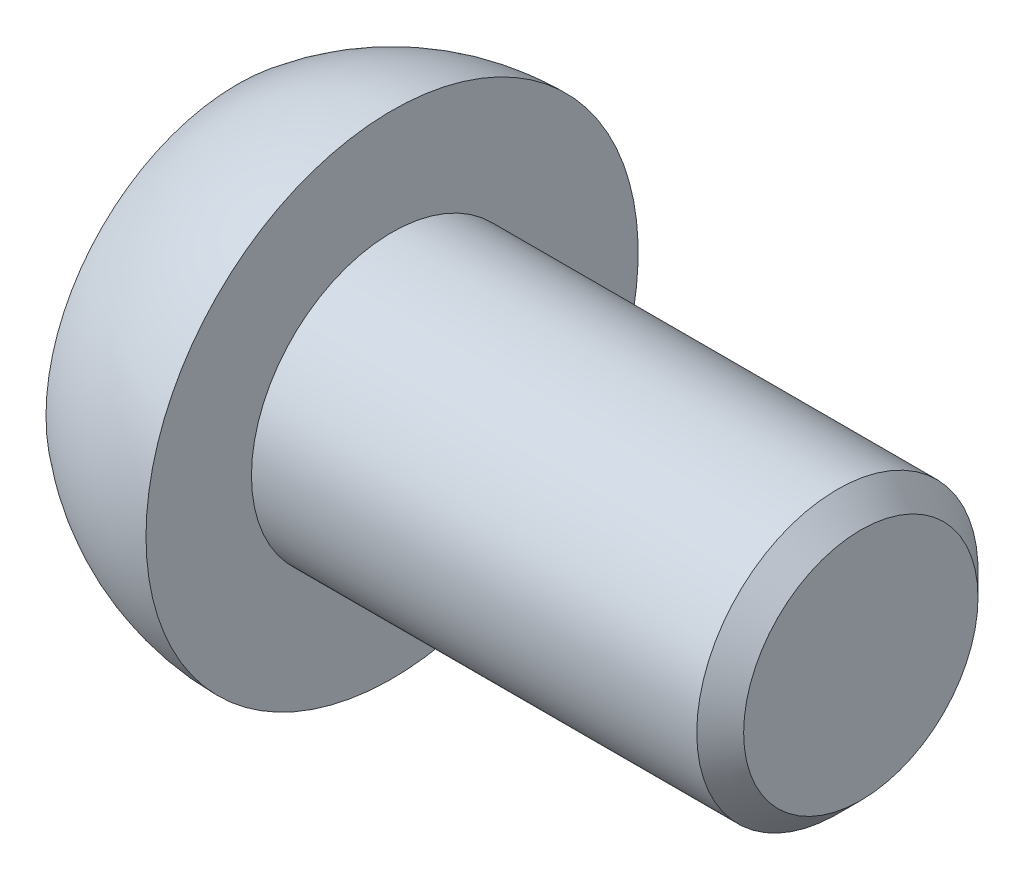
from build123d import *

# Parameters (mm, degrees)
CUT_EXTRUDE_1_DEPTH = 3
FILLET_1_R          = 0.25
CHAMFER_1_SIZE      = 0.5


with BuildPart() as part:
    # Эскиз1 → Повернуть1 (revolve)
    with BuildSketch(Plane.XY):
        with BuildLine():
            Line((0, 5.25), (0, 3))
            Line((0, 3), (10, 3))
            Line((10, 3), (10, 0))
            Line((10, 0), (-3.3, 0))
            Line((-3.3, 0), (-3.3, 4.083197277))
            ThreePointArc((-3.3, 4.083197277), (-1.75010204, 4.949711391), (0, 5.25))
        make_face()
    revolve(axis=Axis((-165.749374514, 0, 0), (1, 0, 0)))

    # Эскиз2 → Вырез-Вытянуть1 (cut)
    with BuildSketch(Plane.ZY.offset(3.3)):
        Polygon((0, -2.309401077), (2, -1.154700538), (2, 1.154700538), (0, 2.309401077), (-2, 1.154700538), (-2, -1.154700538), align=None)
    extrude(amount=-CUT_EXTRUDE_1_DEPTH, mode=Mode.SUBTRACT)

    # Скругление1
    fillet_1_edges = [part.edges().sort_by_distance(p)[0] for p in [
        (-3.3, -1.732050808, -1),
        (-3.3, -1.732050808, 1),
        (-3.3, 0, 2),
        (-3.3, 1.732050808, 1),
        (-3.3, 1.732050808, -1),
        (-3.3, 0, -2),
    ]]
    fillet(fillet_1_edges, radius=FILLET_1_R)

    # Фаска1
    chamfer_1_edges = [part.edges().sort_by_distance(p)[0] for p in [
        (10, -3, 0),
    ]]
    chamfer(chamfer_1_edges, length=CHAMFER_1_SIZE)


solid = part.part
